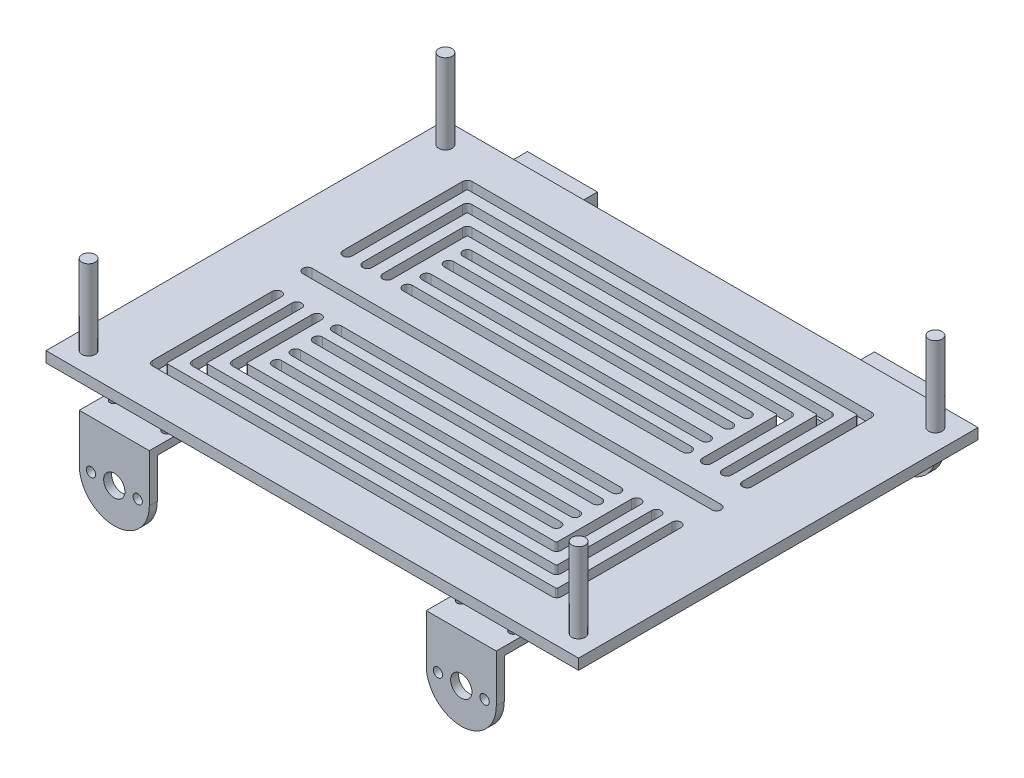
from build123d import *

# Parameters (mm, degrees)
SKETCH_1_W        = 200
SKETCH_1_H        = 150
SKETCH_1_R        = 1.5
EXTRUDE_2_DEPTH   = 4
SKETCH_2_W        = 26.3
SKETCH_2_H        = 29.6
SKETCH_2_R        = 1.5
SKETCH_2_R_2      = 5
EXTRUDE_3_DEPTH   = 3
SKETCH_3_R        = 4
SKETCH_3_R_2      = 1.75
EXTRUDE_4_DEPTH   = 3
SKETCH_4_R        = 4
SKETCH_4_R_2      = 1.75
EXTRUDE_5_DEPTH   = 3
SKETCH_5_R        = 2.5
EXTRUDE_6_DEPTH   = 30
EXTRUDE_6_2_DEPTH = 30
EXTRUDE_6_3_DEPTH = 30
EXTRUDE_6_4_DEPTH = 30


with BuildPart() as part:
    # 草圖1 → 填料-伸長2 (new body)
    with BuildSketch(Plane(origin=(0, 0, 0), x_dir=(1, 0, 0), z_dir=(0, 1, 0))):
        with Locations((0.051092234, 0)):
            Rectangle(SKETCH_1_W, SKETCH_1_H)
        with Locations((-91.948907766, 67)):
            Circle(SKETCH_1_R, mode=Mode.SUBTRACT)
        with Locations((-91.948907766, -67)):
            Circle(SKETCH_1_R, mode=Mode.SUBTRACT)
        with Locations((92.051092234, -67)):
            Circle(SKETCH_1_R, mode=Mode.SUBTRACT)
        with Locations((92.051092234, 67)):
            Circle(SKETCH_1_R, mode=Mode.SUBTRACT)
        with BuildLine():
            Line((-75, 60), (75.102184468, 60))
            ThreePointArc((75.102184468, 60), (76.339621335, 59.487436867), (76.852184468, 58.25))
            Line((76.852184468, 58.25), (76.852184468, 13.25))
            ThreePointArc((76.852184468, 13.25), (75.102184468, 11.5), (73.352184468, 13.25))
            Line((73.352184468, 13.25), (73.352184468, 56))
            ThreePointArc((73.352184468, 56), (73.205737858, 56.353553391), (72.852184468, 56.5))
            Line((72.852184468, 56.5), (-72.75, 56.5))
            ThreePointArc((-72.75, 56.5), (-73.103553391, 56.353553391), (-73.25, 56))
            Line((-73.25, 56), (-73.25, 13.25))
            ThreePointArc((-73.25, 13.25), (-75, 11.5), (-76.75, 13.25))
            Line((-76.75, 13.25), (-76.75, 58.25))
            ThreePointArc((-76.75, 58.25), (-76.237436867, 59.487436867), (-75, 60))
        make_face(mode=Mode.SUBTRACT)
        with BuildLine():
            Line((-52.445567499, -37.5), (52.445567499, -37.5))
            ThreePointArc((52.445567499, -37.5), (54.195567499, -35.75), (52.445567499, -34))
            Line((52.445567499, -34), (-52.445567499, -34))
            ThreePointArc((-52.445567499, -34), (-54.195567499, -35.75), (-52.445567499, -37.5))
        make_face(mode=Mode.SUBTRACT)
        with BuildLine():
            Line((-67.5, 52.5), (67.5, 52.5))
            ThreePointArc((67.5, 52.5), (68.737436867, 51.987436867), (69.25, 50.75))
            Line((69.25, 50.75), (69.25, 13.25))
            ThreePointArc((69.25, 13.25), (67.5, 11.5), (65.75, 13.25))
            Line((65.75, 13.25), (65.75, 48.5))
            ThreePointArc((65.75, 48.5), (65.603553391, 48.853553391), (65.25, 49))
            Line((65.25, 49), (-65.25, 49))
            ThreePointArc((-65.25, 49), (-65.603553391, 48.853553391), (-65.75, 48.5))
            Line((-65.75, 48.5), (-65.75, 13.25))
            ThreePointArc((-65.75, 13.25), (-67.5, 11.5), (-69.25, 13.25))
            Line((-69.25, 13.25), (-69.25, 50.75))
            ThreePointArc((-69.25, 50.75), (-68.737436867, 51.987436867), (-67.5, 52.5))
        make_face(mode=Mode.SUBTRACT)
        with BuildLine():
            Line((-60, 45), (60, 45))
            ThreePointArc((60, 45), (61.237436867, 44.487436867), (61.75, 43.25))
            Line((61.75, 43.25), (61.75, 13.25))
            ThreePointArc((61.75, 13.25), (60, 11.5), (58.25, 13.25))
            Line((58.25, 13.25), (58.25, 41))
            ThreePointArc((58.25, 41), (58.103553391, 41.353553391), (57.75, 41.5))
            Line((57.75, 41.5), (-57.75, 41.5))
            ThreePointArc((-57.75, 41.5), (-58.103553391, 41.353553391), (-58.25, 41))
            Line((-58.25, 41), (-58.25, 13.25))
            ThreePointArc((-58.25, 13.25), (-60, 11.5), (-61.75, 13.25))
            Line((-61.75, 13.25), (-61.75, 43.25))
            ThreePointArc((-61.75, 43.25), (-61.237436867, 44.487436867), (-60, 45))
        make_face(mode=Mode.SUBTRACT)
        with BuildLine():
            Line((-52.445567499, 37.5), (52.445567499, 37.5))
            ThreePointArc((52.445567499, 37.5), (54.195567499, 35.75), (52.445567499, 34))
            Line((52.445567499, 34), (-52.445567499, 34))
            ThreePointArc((-52.445567499, 34), (-54.195567499, 35.75), (-52.445567499, 37.5))
        make_face(mode=Mode.SUBTRACT)
        with BuildLine():
            Line((-52.445567499, 30.5), (52.445567499, 30.5))
            ThreePointArc((52.445567499, 30.5), (54.195567499, 28.75), (52.445567499, 27))
            Line((52.445567499, 27), (-52.445567499, 27))
            ThreePointArc((-52.445567499, 27), (-54.195567499, 28.75), (-52.445567499, 30.5))
        make_face(mode=Mode.SUBTRACT)
        with BuildLine():
            Line((-52.445567499, 22.166913607), (52.445567499, 22.166913607))
            ThreePointArc((52.445567499, 22.166913607), (54.195567499, 20.416913607), (52.445567499, 18.666913607))
            Line((52.445567499, 18.666913607), (-52.445567499, 18.666913607))
            ThreePointArc((-52.445567499, 18.666913607), (-54.195567499, 20.416913607), (-52.445567499, 22.166913607))
        make_face(mode=Mode.SUBTRACT)
        with BuildLine():
            Line((-52.445567499, 15), (52.445567499, 15))
            ThreePointArc((52.445567499, 15), (54.195567499, 13.25), (52.445567499, 11.5))
            Line((52.445567499, 11.5), (-52.445567499, 11.5))
            ThreePointArc((-52.445567499, 11.5), (-54.195567499, 13.25), (-52.445567499, 15))
        make_face(mode=Mode.SUBTRACT)
        with BuildLine():
            Line((-52.445567499, -30.5), (52.445567499, -30.5))
            ThreePointArc((52.445567499, -30.5), (54.195567499, -28.75), (52.445567499, -27))
            Line((52.445567499, -27), (-52.445567499, -27))
            ThreePointArc((-52.445567499, -27), (-54.195567499, -28.75), (-52.445567499, -30.5))
        make_face(mode=Mode.SUBTRACT)
        with BuildLine():
            Line((-52.445567499, -22.166913607), (52.445567499, -22.166913607))
            ThreePointArc((52.445567499, -22.166913607), (54.195567499, -20.416913607), (52.445567499, -18.666913607))
            Line((52.445567499, -18.666913607), (-52.445567499, -18.666913607))
            ThreePointArc((-52.445567499, -18.666913607), (-54.195567499, -20.416913607), (-52.445567499, -22.166913607))
        make_face(mode=Mode.SUBTRACT)
        with BuildLine():
            Line((-52.445567499, -15), (52.445567499, -15))
            ThreePointArc((52.445567499, -15), (54.195567499, -13.25), (52.445567499, -11.5))
            Line((52.445567499, -11.5), (-52.445567499, -11.5))
            ThreePointArc((-52.445567499, -11.5), (-54.195567499, -13.25), (-52.445567499, -15))
        make_face(mode=Mode.SUBTRACT)
        with BuildLine():
            Line((76.852184468, -58.25), (76.852184468, -13.25))
            ThreePointArc((76.852184468, -13.25), (75.102184468, -11.5), (73.352184468, -13.25))
            Line((73.352184468, -13.25), (73.352184468, -56))
            ThreePointArc((73.352184468, -56), (73.205737858, -56.353553391), (72.852184468, -56.5))
            Line((72.852184468, -56.5), (-72.75, -56.5))
            ThreePointArc((-72.75, -56.5), (-73.103553391, -56.353553391), (-73.25, -56))
            Line((-73.25, -56), (-73.25, -13.25))
            ThreePointArc((-73.25, -13.25), (-75, -11.5), (-76.75, -13.25))
            Line((-76.75, -13.25), (-76.75, -58.25))
            ThreePointArc((-76.75, -58.25), (-76.237436867, -59.487436867), (-75, -60))
            Line((-75, -60), (75.102184468, -60))
            ThreePointArc((75.102184468, -60), (76.339621335, -59.487436867), (76.852184468, -58.25))
        make_face(mode=Mode.SUBTRACT)
        with BuildLine():
            Line((69.25, -50.75), (69.25, -13.25))
            ThreePointArc((69.25, -13.25), (67.5, -11.5), (65.75, -13.25))
            Line((65.75, -13.25), (65.75, -48.5))
            ThreePointArc((65.75, -48.5), (65.603553391, -48.853553391), (65.25, -49))
            Line((65.25, -49), (-65.25, -49))
            ThreePointArc((-65.25, -49), (-65.603553391, -48.853553391), (-65.75, -48.5))
            Line((-65.75, -48.5), (-65.75, -13.25))
            ThreePointArc((-65.75, -13.25), (-67.5, -11.5), (-69.25, -13.25))
            Line((-69.25, -13.25), (-69.25, -50.75))
            ThreePointArc((-69.25, -50.75), (-68.737436867, -51.987436867), (-67.5, -52.5))
            Line((-67.5, -52.5), (67.5, -52.5))
            ThreePointArc((67.5, -52.5), (68.737436867, -51.987436867), (69.25, -50.75))
        make_face(mode=Mode.SUBTRACT)
        with BuildLine():
            Line((61.75, -43.25), (61.75, -13.25))
            ThreePointArc((61.75, -13.25), (60, -11.5), (58.25, -13.25))
            Line((58.25, -13.25), (58.25, -41))
            ThreePointArc((58.25, -41), (58.103553391, -41.353553391), (57.75, -41.5))
            Line((57.75, -41.5), (-57.75, -41.5))
            ThreePointArc((-57.75, -41.5), (-58.103553391, -41.353553391), (-58.25, -41))
            Line((-58.25, -41), (-58.25, -13.25))
            ThreePointArc((-58.25, -13.25), (-60, -11.5), (-61.75, -13.25))
            Line((-61.75, -13.25), (-61.75, -43.25))
            ThreePointArc((-61.75, -43.25), (-61.237436867, -44.487436867), (-60, -45))
            Line((-60, -45), (60, -45))
            ThreePointArc((60, -45), (61.237436867, -44.487436867), (61.75, -43.25))
        make_face(mode=Mode.SUBTRACT)
        with BuildLine():
            Line((-76.75, 1.75), (76.852184468, 1.75))
            ThreePointArc((76.852184468, 1.75), (78.602184468, 0), (76.852184468, -1.75))
            Line((76.852184468, -1.75), (-76.75, -1.75))
            ThreePointArc((-76.75, -1.75), (-78.5, 0), (-76.75, 1.75))
        make_face(mode=Mode.SUBTRACT)
    extrude(amount=EXTRUDE_2_DEPTH)

    # 草圖2 → 填料-伸長3 (add)
    with BuildSketch(Plane.XZ):
        with Locations((-65.15, 66.35)):
            Rectangle(SKETCH_2_W, SKETCH_2_H)
        with Locations((-75, 58.25)):
            Circle(SKETCH_2_R, mode=Mode.SUBTRACT)
        with Locations((-65.15, 66.35)):
            Circle(SKETCH_2_R_2, mode=Mode.SUBTRACT)
        with Locations((-55.3, 58.25)):
            Circle(SKETCH_2_R, mode=Mode.SUBTRACT)
        with Locations((-55.3, 74.45)):
            Circle(SKETCH_2_R, mode=Mode.SUBTRACT)
        with Locations((-75, 74.45)):
            Circle(SKETCH_2_R, mode=Mode.SUBTRACT)
        with Locations((-65.15, -66.35)):
            Rectangle(SKETCH_2_W, SKETCH_2_H)
        with Locations((-75, -58.25)):
            Circle(SKETCH_2_R, mode=Mode.SUBTRACT)
        with Locations((-55.3, -58.25)):
            Circle(SKETCH_2_R, mode=Mode.SUBTRACT)
        with Locations((-55.3, -74.45)):
            Circle(SKETCH_2_R, mode=Mode.SUBTRACT)
        with Locations((-65.15, -66.35)):
            Circle(SKETCH_2_R_2, mode=Mode.SUBTRACT)
        with Locations((-75, -74.45)):
            Circle(SKETCH_2_R, mode=Mode.SUBTRACT)
        with Locations((65.15, 66.35)):
            Rectangle(SKETCH_2_W, SKETCH_2_H)
        with Locations((75, 58.25)):
            Circle(SKETCH_2_R, mode=Mode.SUBTRACT)
        with Locations((55.3, 58.25)):
            Circle(SKETCH_2_R, mode=Mode.SUBTRACT)
        with Locations((65.15, 66.35)):
            Circle(SKETCH_2_R_2, mode=Mode.SUBTRACT)
        with Locations((55.3, 74.45)):
            Circle(SKETCH_2_R, mode=Mode.SUBTRACT)
        with Locations((75, 74.45)):
            Circle(SKETCH_2_R, mode=Mode.SUBTRACT)
        with Locations((65.15, -66.35)):
            Rectangle(SKETCH_2_W, SKETCH_2_H)
        with Locations((75, -74.45)):
            Circle(SKETCH_2_R, mode=Mode.SUBTRACT)
        with Locations((55.3, -74.45)):
            Circle(SKETCH_2_R, mode=Mode.SUBTRACT)
        with Locations((65.15, -66.35)):
            Circle(SKETCH_2_R_2, mode=Mode.SUBTRACT)
        with Locations((55.3, -58.25)):
            Circle(SKETCH_2_R, mode=Mode.SUBTRACT)
        with Locations((75, -58.25)):
            Circle(SKETCH_2_R, mode=Mode.SUBTRACT)
    extrude(amount=EXTRUDE_3_DEPTH)

    # 草圖3 → 填料-伸長4 (add)
    with BuildSketch(Plane.XY.offset(81.15)):
        with BuildLine():
            Line((-78.3, 0), (-52, 0))
            Line((-52, 0), (-52, -17.9))
            ThreePointArc((-52, -17.9), (-65.15, -31.05), (-78.3, -17.9))
            Line((-78.3, -17.9), (-78.3, 0))
        make_face()
        with Locations((-65.15, -17.9)):
            Circle(SKETCH_3_R, mode=Mode.SUBTRACT)
        with Locations((-73.925, -17.9)):
            Circle(SKETCH_3_R_2, mode=Mode.SUBTRACT)
        with Locations((-56.375, -17.9)):
            Circle(SKETCH_3_R_2, mode=Mode.SUBTRACT)
        with BuildLine():
            Line((52, 0), (52, -17.9))
            ThreePointArc((52, -17.9), (65.15, -31.05), (78.3, -17.9))
            Line((78.3, -17.9), (78.3, 0))
            Line((78.3, 0), (52, 0))
        make_face()
        with Locations((56.375, -17.9)):
            Circle(SKETCH_3_R_2, mode=Mode.SUBTRACT)
        with Locations((73.925, -17.9)):
            Circle(SKETCH_3_R_2, mode=Mode.SUBTRACT)
        with Locations((65.15, -17.9)):
            Circle(SKETCH_3_R, mode=Mode.SUBTRACT)
    extrude(amount=EXTRUDE_4_DEPTH)

    # 草圖4 → 填料-伸長5 (add)
    with BuildSketch(Plane(origin=(0, 0, -81.15), x_dir=(-1, 0, 0), z_dir=(0, 0, -1))):
        with BuildLine():
            Line((-78.3, 0), (-52, 0))
            Line((-52, 0), (-52, -17.9))
            ThreePointArc((-52, -17.9), (-65.15, -31.05), (-78.3, -17.9))
            Line((-78.3, -17.9), (-78.3, 0))
        make_face()
        with Locations((-65.15, -17.9)):
            Circle(SKETCH_4_R, mode=Mode.SUBTRACT)
        with Locations((-73.925, -17.9)):
            Circle(SKETCH_4_R_2, mode=Mode.SUBTRACT)
        with Locations((-56.375, -17.9)):
            Circle(SKETCH_4_R_2, mode=Mode.SUBTRACT)
        with BuildLine():
            Line((52, 0), (52, -17.9))
            ThreePointArc((52, -17.9), (65.15, -31.05), (78.3, -17.9))
            Line((78.3, -17.9), (78.3, 0))
            Line((78.3, 0), (52, 0))
        make_face()
        with Locations((56.375, -17.9)):
            Circle(SKETCH_4_R_2, mode=Mode.SUBTRACT)
        with Locations((73.925, -17.9)):
            Circle(SKETCH_4_R_2, mode=Mode.SUBTRACT)
        with Locations((65.15, -17.9)):
            Circle(SKETCH_4_R, mode=Mode.SUBTRACT)
    extrude(amount=EXTRUDE_5_DEPTH)


with BuildPart() as body_2:
    # 草圖5 → 填料-伸長6 (new body)
    with BuildSketch(Plane(origin=(0, 4, 0), x_dir=(1, 0, 0), z_dir=(0, 1, 0))):
        with Locations((-91.948907766, 67)):
            Circle(SKETCH_5_R)
    extrude(amount=EXTRUDE_6_DEPTH)


with BuildPart() as body_3:
    # 草圖5 → Extrude 6 2 (new body)
    with BuildSketch(Plane(origin=(0, 4, 0), x_dir=(1, 0, 0), z_dir=(0, 1, 0))):
        with Locations((92.051092234, 67)):
            Circle(SKETCH_5_R)
    extrude(amount=EXTRUDE_6_2_DEPTH)


with BuildPart() as body_4:
    # 草圖5 → Extrude 6 3 (new body)
    with BuildSketch(Plane(origin=(0, 4, 0), x_dir=(1, 0, 0), z_dir=(0, 1, 0))):
        with Locations((92.051092234, -67)):
            Circle(SKETCH_5_R)
    extrude(amount=EXTRUDE_6_3_DEPTH)


with BuildPart() as body_5:
    # 草圖5 → Extrude 6 4 (new body)
    with BuildSketch(Plane(origin=(0, 4, 0), x_dir=(1, 0, 0), z_dir=(0, 1, 0))):
        with Locations((-91.948907766, -67)):
            Circle(SKETCH_5_R)
    extrude(amount=EXTRUDE_6_4_DEPTH)


solid = Compound([part.part, body_2.part, body_3.part, body_4.part, body_5.part])
